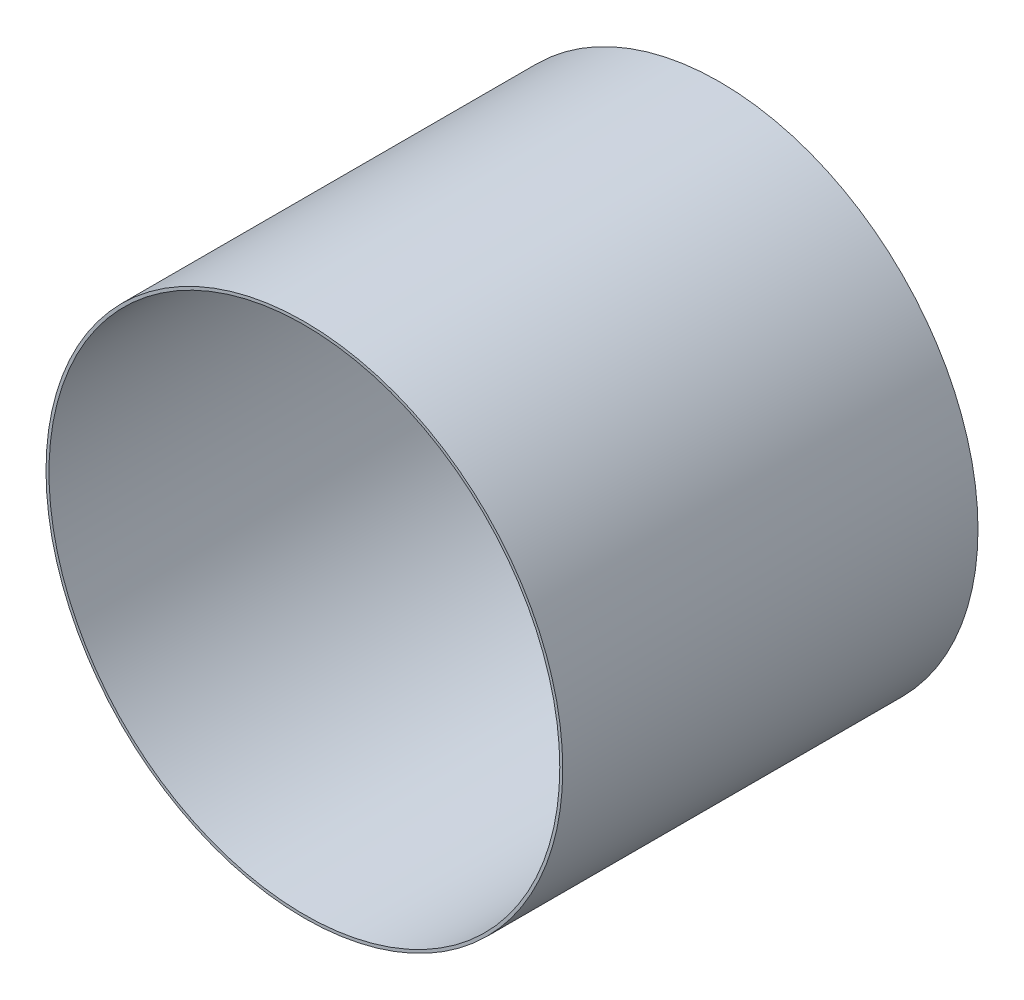
from build123d import *

# Parameters (mm, degrees)
SKETCH1_R           = 87.110994186
SKETCH1_R_2         = 86.110994186
BOSS_EXTRUDE1_DEPTH = 140


with BuildPart() as part:
    # Sketch1 → Boss-Extrude1 (new body)
    with BuildSketch(Plane.XY):
        Circle(SKETCH1_R)
        Circle(SKETCH1_R_2, mode=Mode.SUBTRACT)
    extrude(amount=BOSS_EXTRUDE1_DEPTH)


solid = part.part
